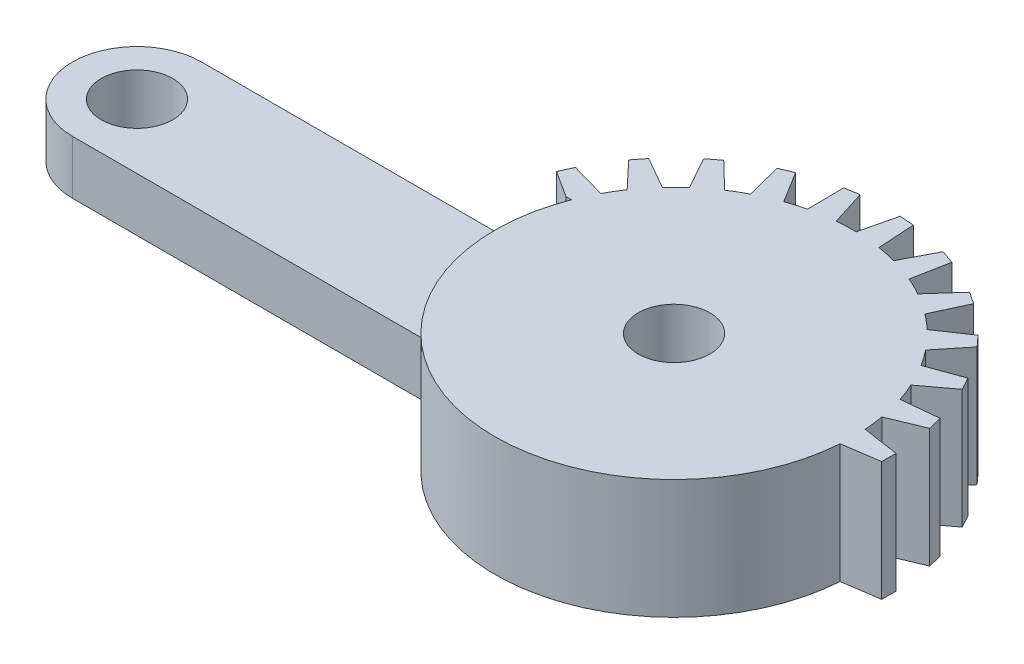
from build123d import *

# Parameters (mm, degrees)
BOSS_EXTRUDE1_DEPTH = 33.333333333
BOSS_EXTRUDE2_DEPTH = 33.333333333
CIRPATTERN2_COUNT   = 13
CIRPATTERN2_ANGLE   = 170
F_20_0MM_1_D        = 20
SCALE_1_SCALE       = 0.3
CUT_EXTRUDE_1_DEPTH = 5.5


with BuildPart() as part:
    # Sketch1 → Boss-Extrude1 (new body)
    with BuildSketch(Plane(origin=(0, 0, 0), x_dir=(1, 0, 0), z_dir=(0, 1, 0))):
        with BuildLine():
            Line((-150, 18), (-46.647615159, 18))
            ThreePointArc((-46.647615159, 18), (50, 0), (-46.647615159, -18))
            Line((-46.647615159, -18), (-150, -18))
            ThreePointArc((-150, -18), (-168, 0), (-150, 18))
        make_face()
    extrude(amount=BOSS_EXTRUDE1_DEPTH)

    # Sketch2 → Boss-Extrude2 (add)
    with BuildSketch(Plane(origin=(0, 33.333333333, 0), x_dir=(1, 0, 0), z_dir=(0, 1, 0))):
        Polygon((49.877349569, 3.5), (60, 2), (60, -2), (49.877349569, -3.5), (50, 0), align=None)
    boss_extrude2 = extrude(amount=-BOSS_EXTRUDE2_DEPTH)

    # CirPattern2: Boss-Extrude2 ×13 about axis
    cirpattern2_axis = Axis((0, 0, 0), (0, 1, 0))
    for i in range(1, CIRPATTERN2_COUNT):
        add(boss_extrude2.rotate(cirpattern2_axis, i * CIRPATTERN2_ANGLE / (CIRPATTERN2_COUNT - 1)))

    # Ø20.0mm 맞춤핀 구멍1 (through all)
    with Locations(Plane(origin=(0, 33.333333333, 0), x_dir=(1, 0, 0), z_dir=(0, 1, 0))):
        with Locations((-150, 0), (0, 0)):
            Hole(F_20_0MM_1_D / 2)


with BuildPart() as part_1:
    # 축척1: scaled about (-32.400752932, 16.666666667, -1.971262661)
    add(part.part.scale(SCALE_1_SCALE).moved(Location((-22.680527052, 11.666666667, -1.379883863))))

    # 스케치1 → 컷-돌출1 (cut)
    with BuildSketch(Plane(origin=(0, 21.666666667, 0), x_dir=(1, 0, 0), z_dir=(0, 1, 0))):
        with BuildLine():
            Line((-36.6748116, -4.020116137), (-67.680527053, -4.020116137))
            ThreePointArc((-67.680527053, -4.020116137), (-73.080527053, 1.379883863), (-67.680527053, 6.779883863))
            Line((-67.680527053, 6.779883863), (-36.6748116, 6.779883863))
            ThreePointArc((-36.6748116, 6.779883863), (-37.680527053, 1.379883863), (-36.6748116, -4.020116137))
        make_face()
    extrude(amount=-CUT_EXTRUDE_1_DEPTH, mode=Mode.SUBTRACT)


solid = part_1.part
